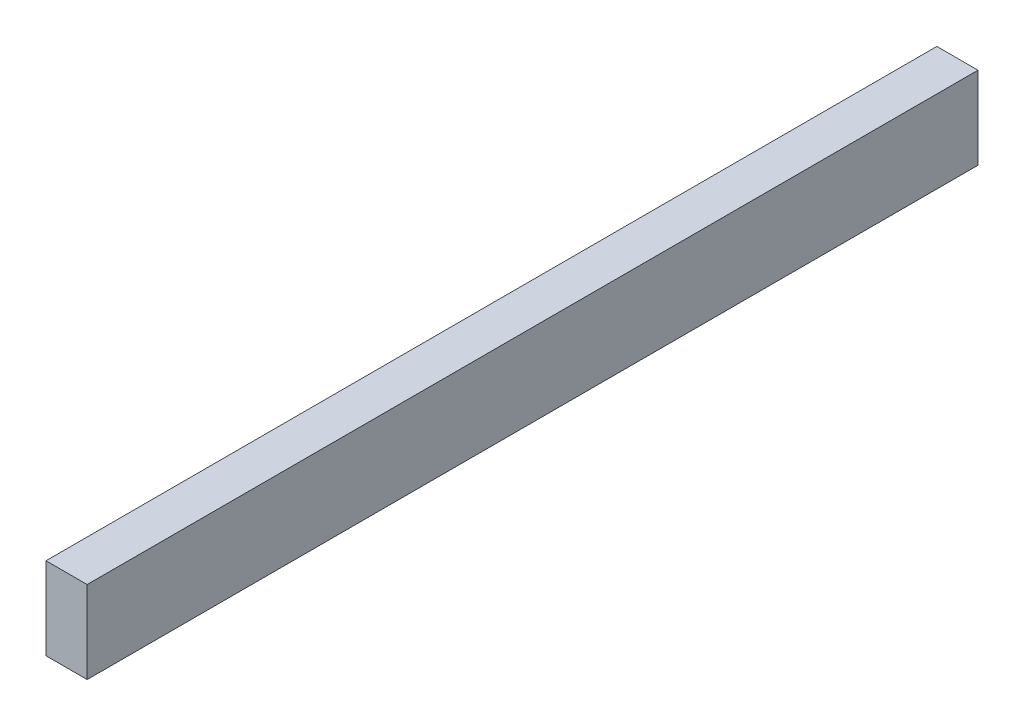
from build123d import *

# Parameters (mm, degrees)
SKETCH1_W           = 412.2928
SKETCH1_H           = 38.1
BOSS_EXTRUDE1_DEPTH = 19.05


with BuildPart() as part:
    # Sketch1 → Boss-Extrude1 (new body)
    with BuildSketch(Plane(origin=(0, 0, 0), x_dir=(0, 0, -1), z_dir=(1, 0, 0))):
        with Locations((87.039591111, -30.768713333)):
            Rectangle(SKETCH1_W, SKETCH1_H)
    extrude(amount=BOSS_EXTRUDE1_DEPTH)


solid = part.part
